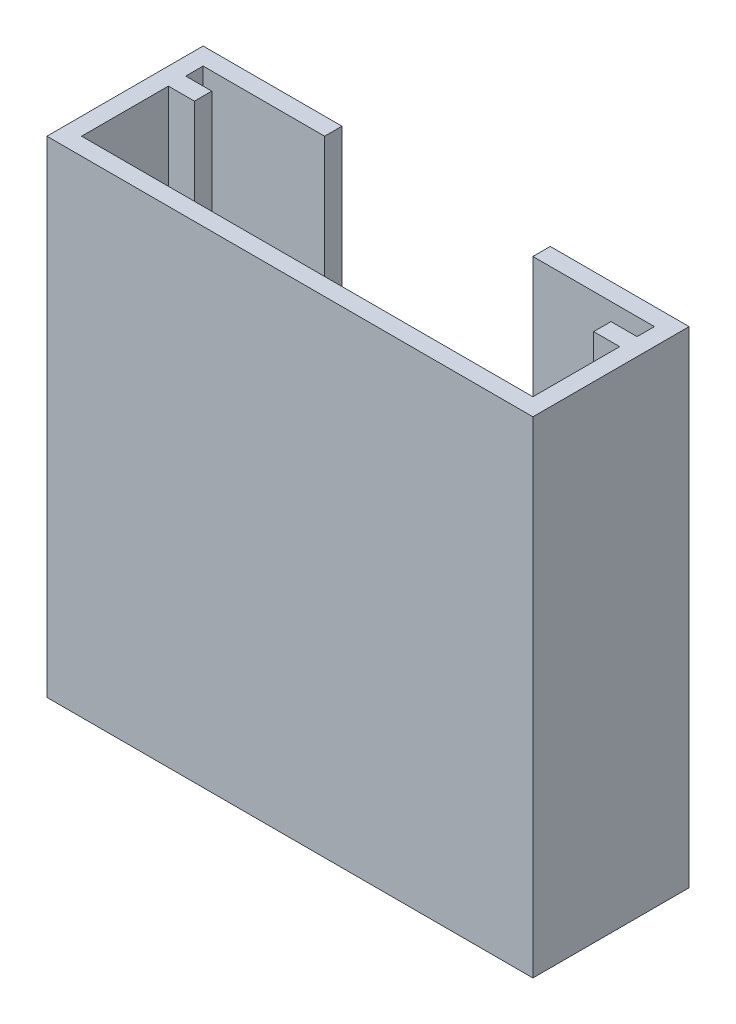
from build123d import *

# Parameters (mm, degrees)
EXTRUDE_1_DEPTH = 1
EXTRUDE_2_DEPTH = 7
SKETCH_5_W      = 1
SKETCH_5_H      = 27
EXTRUDE_3_DEPTH = 1.5
SKETCH_7_W      = 1
SKETCH_7_H      = 27
EXTRUDE_4_DEPTH = 1.5
SKETCH_8_W      = 28
SKETCH_8_H      = 28
EXTRUDE_5_DEPTH = 1


with BuildPart() as part:
    # 스케치1 → 보스-돌출1 (new body)
    with BuildSketch(Plane.XY):
        Polygon((20, 0), (28, 0), (28, -28), (0, -28), (0, 0), (8, 0), (8, -23), (20, -23), align=None)
    extrude(amount=EXTRUDE_1_DEPTH)

    # 스케치3 → 보스-돌출2 (add)
    with BuildSketch(Plane.XY.offset(1)):
        Polygon((1, 0), (0, 0), (0, -28), (28, -28), (28, 0), (27, 0), (27, -27), (1, -27), align=None)
    extrude(amount=EXTRUDE_2_DEPTH)

    # 스케치5 → 보스-돌출3 (add)
    with BuildSketch(Plane(origin=(1, 0, 0), x_dir=(0, 0, -1), z_dir=(1, 0, 0))):
        with Locations((-2.5, -13.5)):
            Rectangle(SKETCH_5_W, SKETCH_5_H)
    extrude(amount=EXTRUDE_3_DEPTH)

    # 스케치7 → 보스-돌출4 (add)
    with BuildSketch(Plane.ZY.offset(-27)):
        with Locations((2.5, -13.5)):
            Rectangle(SKETCH_7_W, SKETCH_7_H)
    extrude(amount=EXTRUDE_4_DEPTH)

    # 스케치8 → 보스-돌출5 (add)
    with BuildSketch(Plane.XY.offset(8)):
        with Locations((14, -14)):
            Rectangle(SKETCH_8_W, SKETCH_8_H)
    extrude(amount=EXTRUDE_5_DEPTH)


solid = part.part
